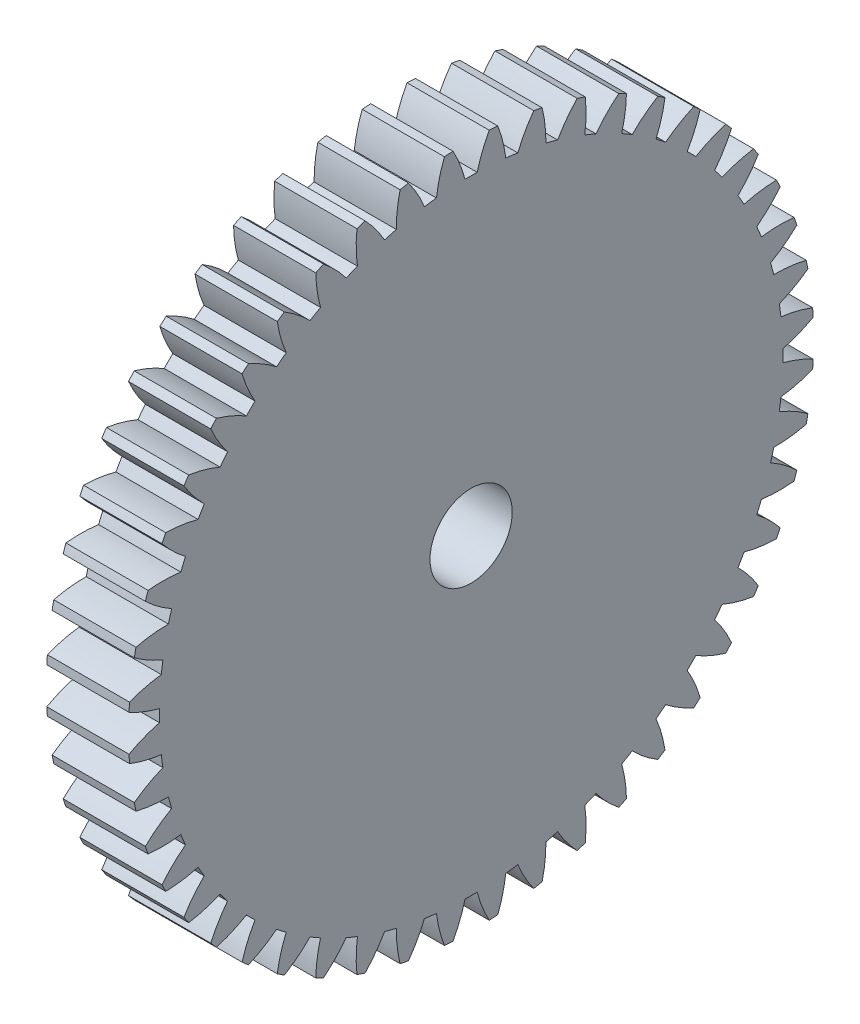
from build123d import *

# Parameters (mm, degrees)
BASPROSKE_W     = 12.7
BASPROSKE_H     = 52.916666667
TOOTHCUT_DEPTH  = 76.905449226
TEETHCUTS_COUNT = 48
TEETHCUTS_ANGLE = 352.5
BORSKE_R        = 6.35
BORE_DEPTH      = 50.8000508


with BuildPart() as part:
    # BasProSke → Base-Revolve (revolve)
    with BuildSketch(Plane(origin=(0, 0, 0), x_dir=(1, 0, 0), z_dir=(0, 1, 0)), mode=Mode.PRIVATE) as base_revolve_sk:
        with Locations((6.35, 26.458333334)):
            Rectangle(BASPROSKE_W, BASPROSKE_H)
    revolve(base_revolve_sk.sketch.rotate(Axis((-10, 0, 0), (1, 0, 0)), 180), axis=Axis((-10, 0, 0), (1, 0, 0)))

    # TooCutSke → ToothCut (cut, through all)
    with BuildSketch(Plane(origin=(0, 0, 0), x_dir=(0, 0, -1), z_dir=(1, 0, 0))):
        with BuildLine():
            ThreePointArc((0.938681533, 48.143746576), (0, 48.152896667), (-0.938681533, 48.143746576))
            ThreePointArc((-0.938681533, 48.143746576), (-1.729356878, 50.56436869), (-2.816577529, 52.86709103))
            ThreePointArc((-2.816577529, 52.86709103), (0, 52.942066667), (2.816577529, 52.86709103))
            ThreePointArc((2.816577529, 52.86709103), (1.729356878, 50.56436869), (0.938681533, 48.143746576))
        make_face()
    toothcut = extrude(amount=TOOTHCUT_DEPTH, mode=Mode.SUBTRACT)

    # TeethCuts: ToothCut ×48 about axis
    teethcuts_axis = Axis((-10, 0, 0), (1, 0, 0))
    for i in range(1, TEETHCUTS_COUNT):
        add(toothcut.rotate(teethcuts_axis, i * TEETHCUTS_ANGLE / (TEETHCUTS_COUNT - 1)), mode=Mode.SUBTRACT)

    # BorSke → Bore (cut, symmetric)
    with BuildSketch(Plane(origin=(0, 0, 0), x_dir=(0, 0, -1), z_dir=(1, 0, 0))):
        with Locations(Location((0, 0, 0), (0, 0, 180))):
            Circle(BORSKE_R)
    extrude(amount=BORE_DEPTH, both=True, mode=Mode.SUBTRACT)


solid = part.part
